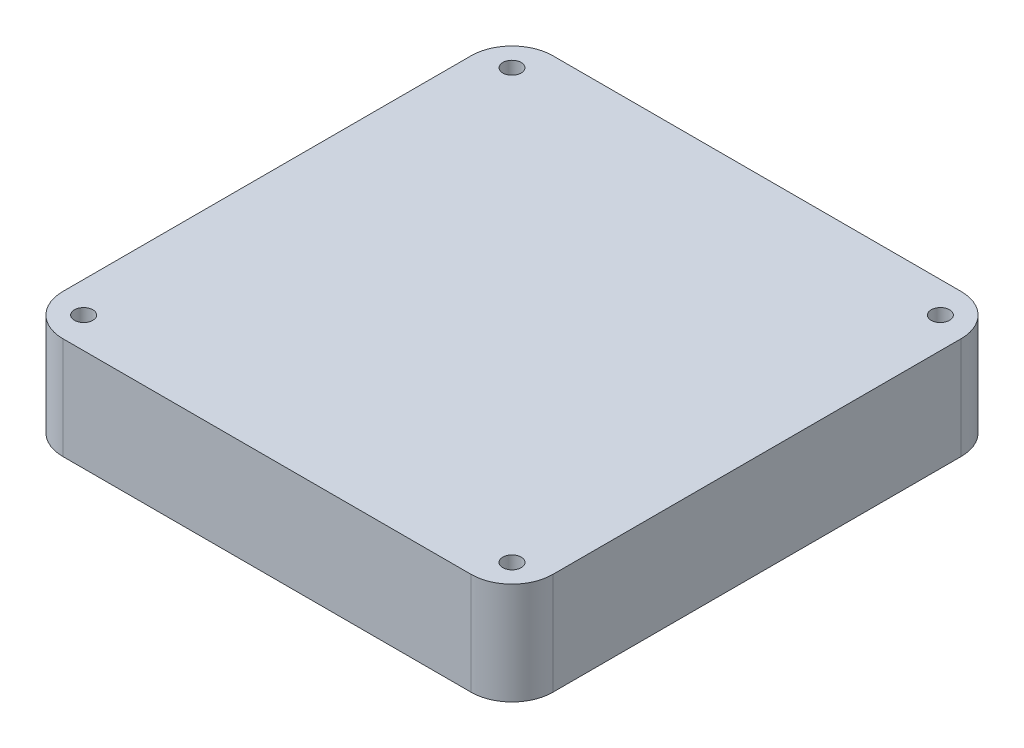
from build123d import *

# Parameters (mm, degrees)
SKETCH_1_W      = 120
SKETCH_1_H      = 120
SKETCH_1_R      = 2.25
EXTRUDE_1_DEPTH = 25
FILLET_1_R      = 10


with BuildPart() as part:
    # Эскиз1 → Бобышка-Вытянуть1 (new body)
    with BuildSketch(Plane(origin=(0, 0, 0), x_dir=(1, 0, 0), z_dir=(0, 1, 0))):
        with Locations((60, 60)):
            Rectangle(SKETCH_1_W, SKETCH_1_H)
        with Locations((7.55, 112.45)):
            Circle(SKETCH_1_R, mode=Mode.SUBTRACT)
        with Locations((112.45, 112.45)):
            Circle(SKETCH_1_R, mode=Mode.SUBTRACT)
        with Locations((112.45, 7.55)):
            Circle(SKETCH_1_R, mode=Mode.SUBTRACT)
        with Locations((7.55, 7.55)):
            Circle(SKETCH_1_R, mode=Mode.SUBTRACT)
    extrude(amount=EXTRUDE_1_DEPTH)

    # Скругление1
    fillet_1_edges = [part.edges().sort_by_distance(p)[0] for p in [
        (0, 12.5, -120),
        (120, 12.5, -120),
        (120, 12.5, 0),
        (0, 12.5, 0),
    ]]
    fillet(fillet_1_edges, radius=FILLET_1_R)


solid = part.part
